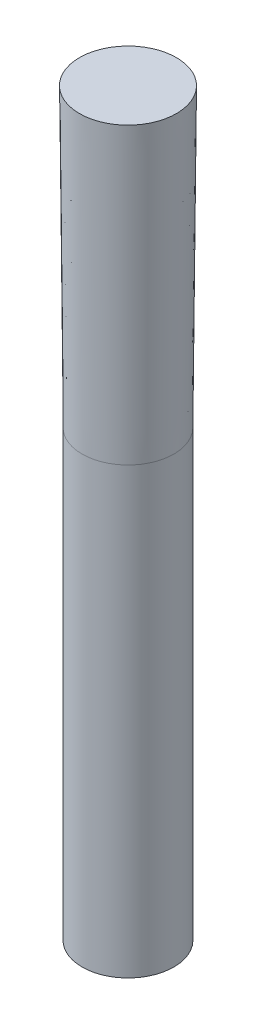
from build123d import *

# Parameters (mm, degrees)
SKICA1_R                = 3.1
P_IDAT_VYSUNUT_M1_DEPTH = 30
SKICA2_R                = 3.1
P_IDAT_VYSUNUT_M2_DEPTH = 20
P_IDAT_VYSUNUT_M2_TAPER = -0.5


with BuildPart() as part:
    # Skica1 → Přidat vysunutím1 (new body)
    with BuildSketch(Plane(origin=(0, 0, 0), x_dir=(1, 0, 0), z_dir=(0, 1, 0))):
        Circle(SKICA1_R)
    extrude(amount=P_IDAT_VYSUNUT_M1_DEPTH)

    # Skica2 → Přidat vysunutím2 (add)
    with BuildSketch(Plane(origin=(0, 30, 0), x_dir=(1, 0, 0), z_dir=(0, 1, 0))):
        Circle(SKICA2_R)
    extrude(amount=P_IDAT_VYSUNUT_M2_DEPTH, taper=P_IDAT_VYSUNUT_M2_TAPER)


solid = part.part
